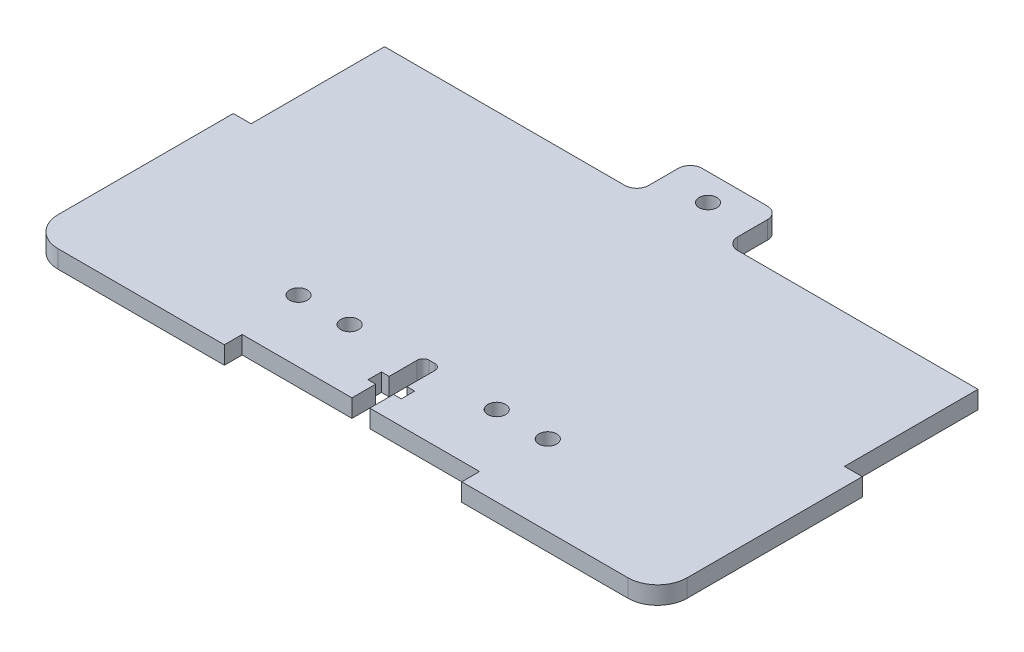
from build123d import *

# Parameters (mm, degrees)
SKETCH1_W               = 106
SKETCH1_H               = 57
BOSS_EXTRUDE1_DEPTH     = 1.5
SKETCH2_W               = 3
SKETCH2_H               = 22.5
SKETCH2_W_2             = 40
SKETCH2_H_2             = 3
CUT_EXTRUDE1_DEPTH      = 2.5
CUT_EXTRUDE1_DEPTH_BACK = 2.5
SKETCH4_W               = 15
SKETCH4_H               = 9
BOSS_EXTRUDE2_DEPTH     = 1.5
FILLET1_R               = 2
CUT_EXTRUDE2_DEPTH      = 2.5
CUT_EXTRUDE2_DEPTH_BACK = 2.5
SKETCH5_R               = 1.5
CUT_EXTRUDE3_DEPTH      = 2.5
CUT_EXTRUDE3_DEPTH_BACK = 2.5
FILLET2_R               = 5
SKETCH6_R               = 1.5
CUT_EXTRUDE4_DEPTH      = 2.5
CUT_EXTRUDE4_DEPTH_BACK = 2.5


with BuildPart() as part:
    # Sketch1 → Boss-Extrude1 (new body, symmetric)
    with BuildSketch(Plane(origin=(0, 0, 0), x_dir=(1, 0, 0), z_dir=(0, 1, 0))):
        Rectangle(SKETCH1_W, SKETCH1_H)
    extrude(amount=BOSS_EXTRUDE1_DEPTH, both=True)

    # Sketch2 → Cut-Extrude1 (cut, two sides)
    with BuildSketch(Plane(origin=(0, 0, 0), x_dir=(1, 0, 0), z_dir=(0, 1, 0))) as cut_extrude1_sk:
        with Locations((-51.5, 17.25)):
            Rectangle(SKETCH2_W, SKETCH2_H)
        with Locations((51.5, 17.25)):
            Rectangle(SKETCH2_W, SKETCH2_H)
        with Locations((0, -27)):
            Rectangle(SKETCH2_W_2, SKETCH2_H_2)
    extrude(amount=CUT_EXTRUDE1_DEPTH, mode=Mode.SUBTRACT)
    extrude(cut_extrude1_sk.sketch, amount=-CUT_EXTRUDE1_DEPTH_BACK, mode=Mode.SUBTRACT)

    # Sketch4 → Boss-Extrude2 (add, symmetric)
    with BuildSketch(Plane(origin=(0, 0, 0), x_dir=(1, 0, 0), z_dir=(0, 1, 0))):
        with Locations((0, 33)):
            Rectangle(SKETCH4_W, SKETCH4_H)
    extrude(amount=BOSS_EXTRUDE2_DEPTH, both=True)

    # Fillet1
    fillet1_edges = [part.edges().sort_by_distance(p)[0] for p in [
        (-7.5, 0, -37.5),
        (-7.5, 0, -28.5),
        (7.5, 0, -28.5),
        (7.5, 0, -37.5),
    ]]
    fillet(fillet1_edges, radius=FILLET1_R)

    # Sketch3 → Cut-Extrude2 (cut, two sides)
    with BuildSketch(Plane(origin=(0, 0, 0), x_dir=(1, 0, 0), z_dir=(0, 1, 0))) as cut_extrude2_sk:
        with BuildLine():
            Line((-1.5, -25.5), (1.5, -25.5))
            Line((1.5, -25.5), (1.5, -21.5))
            Line((1.5, -21.5), (2.8, -21.5))
            Line((2.8, -21.5), (2.8, -19.23))
            Line((2.8, -19.23), (1.5, -19.23))
            Line((1.5, -19.23), (1.5, -14.5))
            ThreePointArc((1.5, -14.5), (1.207106781, -13.792893219), (0.5, -13.5))
            Line((0.5, -13.5), (-0.5, -13.5))
            ThreePointArc((-0.5, -13.5), (-1.207106781, -13.792893219), (-1.5, -14.5))
            Line((-1.5, -14.5), (-1.5, -19.23))
            Line((-1.5, -19.23), (-2.8, -19.23))
            Line((-2.8, -19.23), (-2.8, -21.5))
            Line((-2.8, -21.5), (-1.5, -21.5))
            Line((-1.5, -21.5), (-1.5, -25.5))
        make_face()
    extrude(amount=CUT_EXTRUDE2_DEPTH, mode=Mode.SUBTRACT)
    extrude(cut_extrude2_sk.sketch, amount=-CUT_EXTRUDE2_DEPTH_BACK, mode=Mode.SUBTRACT)

    # Sketch5 → Cut-Extrude3 (cut, two sides)
    with BuildSketch(Plane(origin=(0, 0, 0), x_dir=(1, 0, 0), z_dir=(0, 1, 0))) as cut_extrude3_sk:
        with Locations((0, 33)):
            Circle(SKETCH5_R)
    extrude(amount=CUT_EXTRUDE3_DEPTH, mode=Mode.SUBTRACT)
    extrude(cut_extrude3_sk.sketch, amount=-CUT_EXTRUDE3_DEPTH_BACK, mode=Mode.SUBTRACT)

    # Fillet2
    fillet2_edges = [part.edges().sort_by_distance(p)[0] for p in [
        (53, 0, 28.5),
        (-53, 0, 28.5),
    ]]
    fillet(fillet2_edges, radius=FILLET2_R)

    # Sketch6 → Cut-Extrude4 (cut, two sides)
    with BuildSketch(Plane(origin=(0, 0, 0), x_dir=(1, 0, 0), z_dir=(0, 1, 0))) as cut_extrude4_sk:
        with Locations((-21, -15)):
            Circle(SKETCH6_R)
        with Locations((-12.4, -15)):
            Circle(SKETCH6_R)
        with Locations((12.4, -15)):
            Circle(SKETCH6_R)
        with Locations((21, -15)):
            Circle(SKETCH6_R)
    extrude(amount=CUT_EXTRUDE4_DEPTH, mode=Mode.SUBTRACT)
    extrude(cut_extrude4_sk.sketch, amount=-CUT_EXTRUDE4_DEPTH_BACK, mode=Mode.SUBTRACT)


solid = part.part
